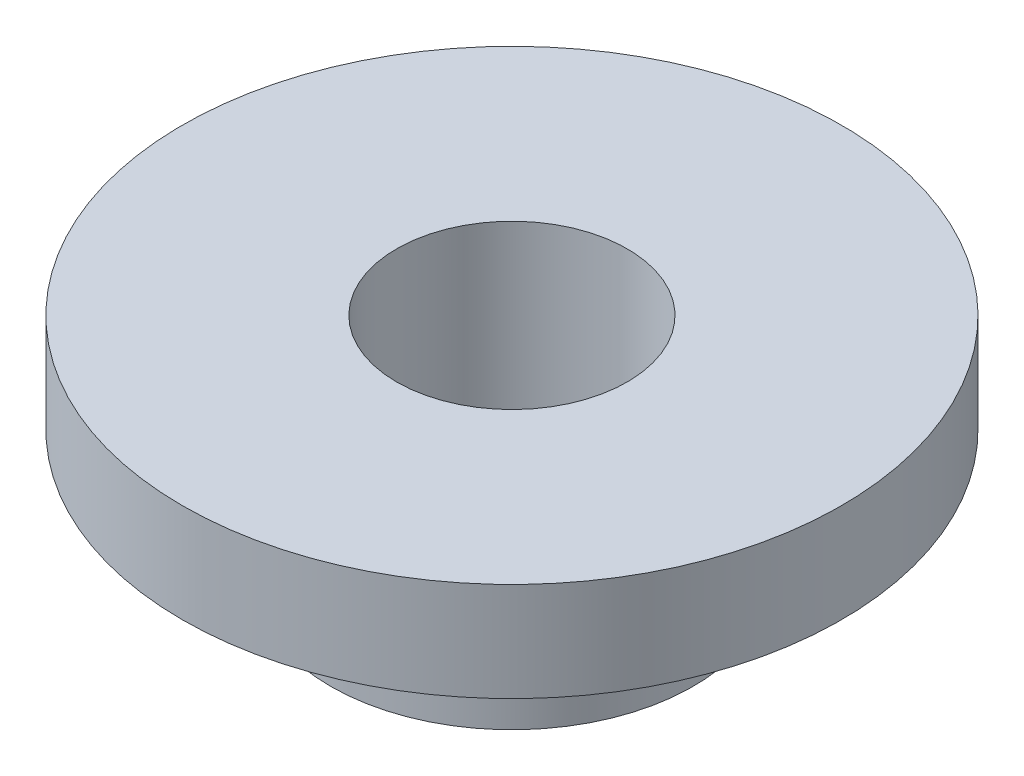
from build123d import *

# Parameters (mm, degrees)
SKETCH1_R           = 57.15
SKETCH1_R_2         = 1.397
SKETCH1_R_3         = 3.175
BOSS_EXTRUDE1_DEPTH = 4.572
SKETCH2_R           = 2.75
SKETCH2_R_2         = 1.75
BOSS_EXTRUDE2_DEPTH = 2
SKETCH3_R           = 5
SKETCH3_R_2         = 1.75
BOSS_EXTRUDE3_DEPTH = 1.5


with BuildPart() as part:
    # Sketch1 → Boss-Extrude1 (new body)
    with BuildSketch(Plane(origin=(0, 0, 0), x_dir=(1, 0, 0), z_dir=(0, 1, 0))):
        Circle(SKETCH1_R)
        with Locations((0, 6.35)):
            Circle(SKETCH1_R_2, mode=Mode.SUBTRACT)
        with Locations((0, 25.4)):
            Circle(SKETCH1_R_3, mode=Mode.SUBTRACT)
        with Locations((0, 50.8)):
            Circle(SKETCH1_R_3, mode=Mode.SUBTRACT)
        with Locations((25.4, 0)):
            Circle(SKETCH1_R_3, mode=Mode.SUBTRACT)
        with Locations((0, -25.4)):
            Circle(SKETCH1_R_3, mode=Mode.SUBTRACT)
        with Locations((-25.4, 0)):
            Circle(SKETCH1_R_3, mode=Mode.SUBTRACT)
        with Locations((6.35, 0)):
            Circle(SKETCH1_R_2, mode=Mode.SUBTRACT)
        with Locations((0, -6.35)):
            Circle(SKETCH1_R_2, mode=Mode.SUBTRACT)
        with Locations((-6.35, 0)):
            Circle(SKETCH1_R_2, mode=Mode.SUBTRACT)
        with Locations((35.921024484, 35.921024484)):
            Circle(SKETCH1_R_3, mode=Mode.SUBTRACT)
        with Locations((50.8, 0)):
            Circle(SKETCH1_R_3, mode=Mode.SUBTRACT)
        with Locations((35.921024484, -35.921024484)):
            Circle(SKETCH1_R_3, mode=Mode.SUBTRACT)
        with Locations((0, -50.8)):
            Circle(SKETCH1_R_3, mode=Mode.SUBTRACT)
        with Locations((-35.921024484, -35.921024484)):
            Circle(SKETCH1_R_3, mode=Mode.SUBTRACT)
        with Locations((-50.8, 0)):
            Circle(SKETCH1_R_3, mode=Mode.SUBTRACT)
        with Locations((-35.921024484, 35.921024484)):
            Circle(SKETCH1_R_3, mode=Mode.SUBTRACT)
    extrude(amount=BOSS_EXTRUDE1_DEPTH)


with BuildPart() as body_2:
    # Sketch2 → Boss-Extrude2 (new body)
    with BuildSketch(Plane(origin=(0, 4.572, 0), x_dir=(1, 0, 0), z_dir=(0, 1, 0))):
        with Locations((-25.4, 0)):
            Circle(SKETCH2_R)
        with Locations((-25.4, 0)):
            Circle(SKETCH2_R_2, mode=Mode.SUBTRACT)
    extrude(amount=-BOSS_EXTRUDE2_DEPTH)

    # Sketch3 → Boss-Extrude3 (add)
    with BuildSketch(Plane(origin=(0, 4.572, 0), x_dir=(1, 0, 0), z_dir=(0, 1, 0))):
        with Locations((-25.4, 0)):
            Circle(SKETCH3_R)
        with Locations((-25.4, 0)):
            Circle(SKETCH3_R_2, mode=Mode.SUBTRACT)
    extrude(amount=BOSS_EXTRUDE3_DEPTH)


solid = body_2.part
